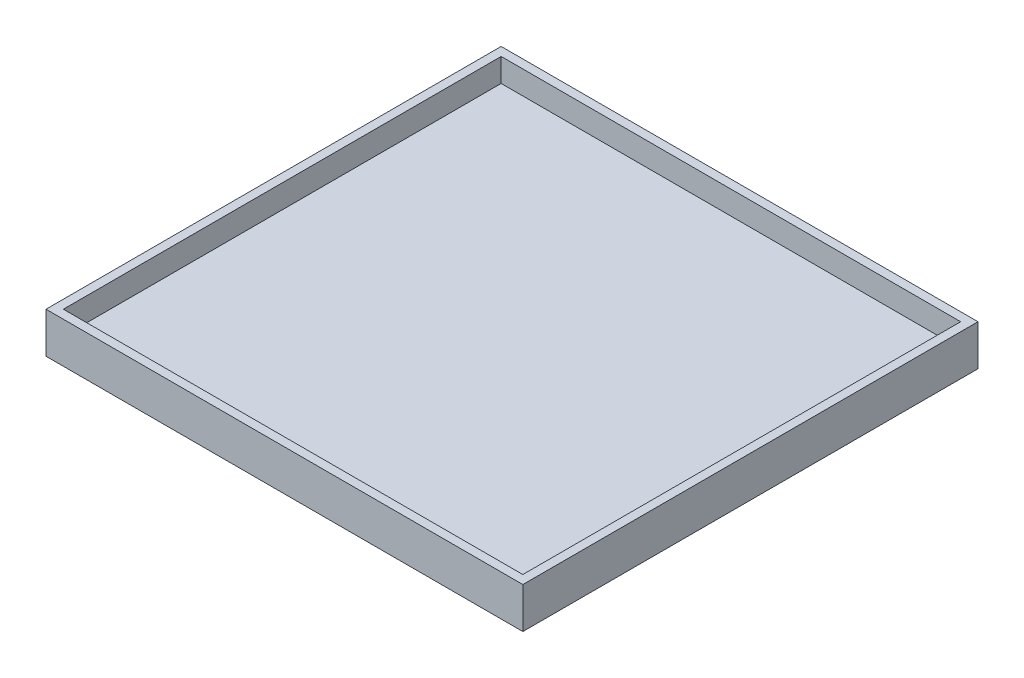
from build123d import *

# Parameters (mm, degrees)
SKETCH1_W           = 110
SKETCH1_H           = 105
SKETCH1_W_2         = 106
SKETCH1_H_2         = 101
BOSS_EXTRUDE1_DEPTH = 5.4
SKETCH2_W           = 110
SKETCH2_H           = 105
BOSS_EXTRUDE2_DEPTH = 4


with BuildPart() as part:
    # Sketch1 → Boss-Extrude1 (new body)
    with BuildSketch(Plane(origin=(0, 0, 0), x_dir=(1, 0, 0), z_dir=(0, 1, 0))):
        Rectangle(SKETCH1_W, SKETCH1_H)
        Rectangle(SKETCH1_W_2, SKETCH1_H_2, mode=Mode.SUBTRACT)
    extrude(amount=-BOSS_EXTRUDE1_DEPTH)

    # Sketch2 → Boss-Extrude2 (add)
    with BuildSketch(Plane.XZ.offset(5.4)):
        Rectangle(SKETCH2_W, SKETCH2_H)
    extrude(amount=BOSS_EXTRUDE2_DEPTH)


solid = part.part
